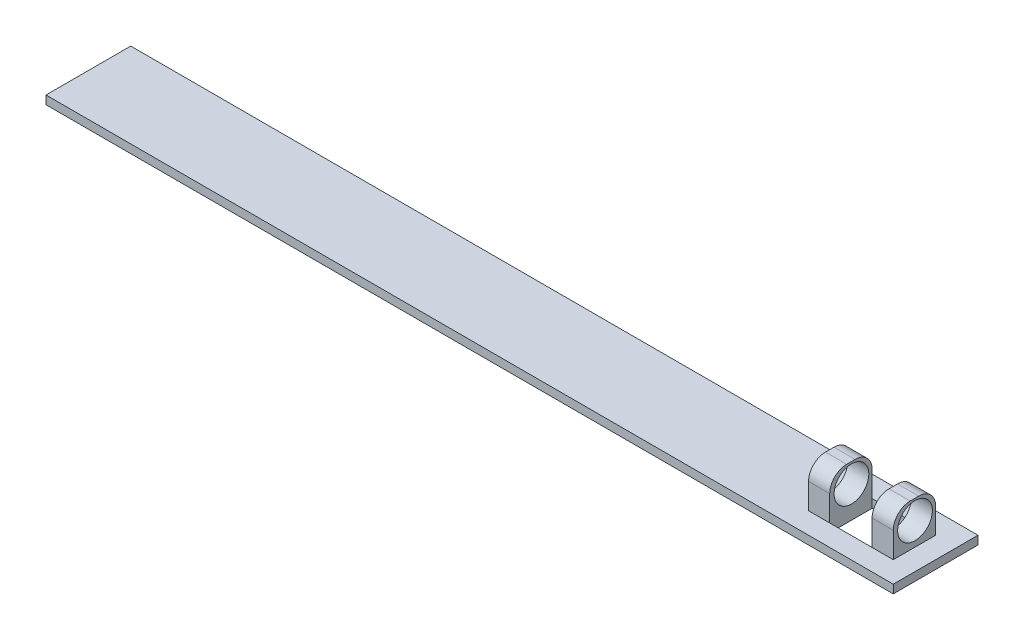
from build123d import *

# Parameters (mm, degrees)
SKETCH1_W             = 2.5
SKETCH1_H             = 5
BOSS_EXTRUDE1_DEPTH   = 5
BOSS_EXTRUDE1_2_DEPTH = 5
SKETCH1_3_W           = 100
SKETCH1_3_H           = 10
BOSS_EXTRUDE2_DEPTH   = 1
SKETCH1_4_W           = 2.5
SKETCH1_4_H           = 5
BOSS_EXTRUDE3_DEPTH   = 1
SKETCH2_R             = 2.05
CUT_EXTRUDE1_DEPTH    = 99.138932132
FILLET1_R             = 2


with BuildPart() as part:
    # Sketch1 → Boss-Extrude1 (new body)
    with BuildSketch(Plane(origin=(0, 0, 0), x_dir=(1, 0, 0), z_dir=(0, 1, 0))):
        with Locations((88.75, 5)):
            Rectangle(SKETCH1_W, SKETCH1_H)
    extrude(amount=BOSS_EXTRUDE1_DEPTH)



with BuildPart() as body_2:
    # Sketch1 → Boss-Extrude1 2 (new body)
    with BuildSketch(Plane(origin=(0, 0, 0), x_dir=(1, 0, 0), z_dir=(0, 1, 0))):
        with Locations((96.25, 5)):
            Rectangle(SKETCH1_W, SKETCH1_H)
    extrude(amount=BOSS_EXTRUDE1_2_DEPTH)


with BuildPart() as body_3:
    # Sketch1_3 → Boss-Extrude2 (new body)
    with BuildSketch(Plane(origin=(0, 0, 0), x_dir=(1, 0, 0), z_dir=(0, 1, 0))):
        with Locations((50, 5)):
            Rectangle(SKETCH1_3_W, SKETCH1_3_H)
        Polygon((90, 2.5), (87.5, 2.5), (87.5, 7.5), (90, 7.5), (95, 7.5), (97.5, 7.5), (97.5, 2.5), (95, 2.5), align=None, mode=Mode.SUBTRACT)
    extrude(amount=-BOSS_EXTRUDE2_DEPTH)


with BuildPart() as part_1:
    add(part.part)

    add(body_2.part)  # Boss-Extrude3 merges body 2

    add(body_3.part)  # Boss-Extrude3 merges body 3
    # Sketch1_4 → Boss-Extrude3 (add)
    with BuildSketch(Plane(origin=(0, 0, 0), x_dir=(1, 0, 0), z_dir=(0, 1, 0))):
        with Locations((88.75, 5)):
            Rectangle(SKETCH1_4_W, SKETCH1_4_H)
        with Locations((96.25, 5)):
            Rectangle(SKETCH1_4_W, SKETCH1_4_H)
    extrude(amount=-BOSS_EXTRUDE3_DEPTH)

    # Sketch2 → Cut-Extrude1 (cut, through all)
    with BuildSketch(Plane(origin=(97.5, 0, 0), x_dir=(0, 0, -1), z_dir=(1, 0, 0))):
        with Locations((5.065113553, 2.710102322)):
            Circle(SKETCH2_R)
    extrude(amount=-CUT_EXTRUDE1_DEPTH, mode=Mode.SUBTRACT)

    # Fillet1
    fillet1_edges = [part_1.edges().sort_by_distance(p)[0] for p in [
        (96.25, 5, -7.5),
        (88.75, 5, -7.5),
        (96.25, 5, -2.5),
        (88.75, 5, -2.5),
    ]]
    fillet(fillet1_edges, radius=FILLET1_R)


solid = part_1.part
